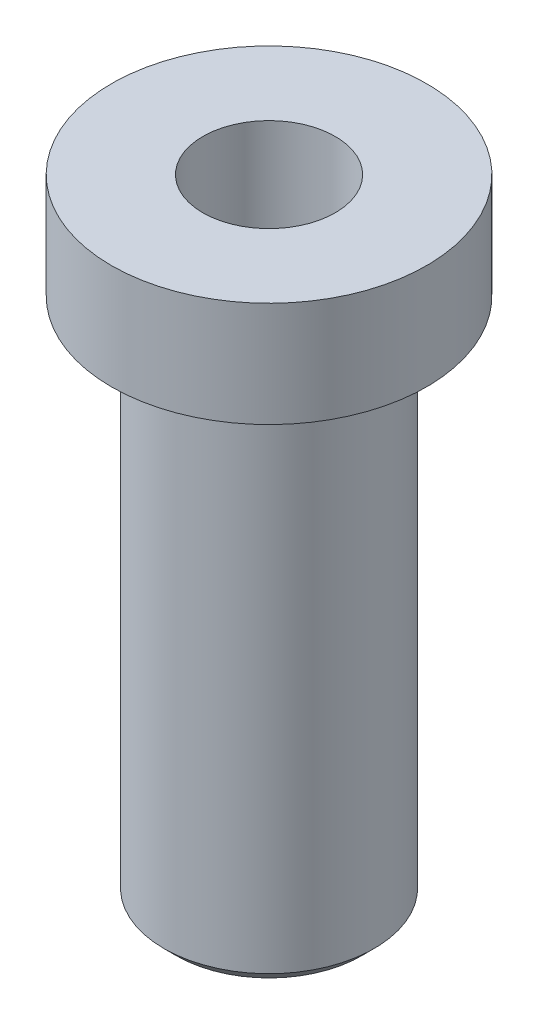
from build123d import *

# Parameters (mm, degrees)
SKETCH1_R           = 0.5
BOSS_EXTRUDE1_DEPTH = 3
SKETCH2_R           = 0.75
BOSS_EXTRUDE2_DEPTH = 0.5
CHAMFER1_SIZE       = 0.06
CUT_EXTRUDE1_START  = 3
SKETCH3_R           = 0.315
CUT_EXTRUDE1_DEPTH  = 4


with BuildPart() as part:
    # Sketch1 → Boss-Extrude1 (new body)
    with BuildSketch(Plane(origin=(0, 0, 0), x_dir=(1, 0, 0), z_dir=(0, 1, 0))):
        Circle(SKETCH1_R)
    extrude(amount=BOSS_EXTRUDE1_DEPTH)

    # Sketch2 → Boss-Extrude2 (add)
    with BuildSketch(Plane(origin=(0, 3, 0), x_dir=(1, 0, 0), z_dir=(0, 1, 0))):
        Circle(SKETCH2_R)
    extrude(amount=-BOSS_EXTRUDE2_DEPTH)

    # Chamfer1
    chamfer1_edges = [part.edges().sort_by_distance(p)[0] for p in [
        (-0.5, 0, 0),
    ]]
    chamfer(chamfer1_edges, length=CHAMFER1_SIZE)

    # Sketch3 → Cut-Extrude1 (cut, through all)
    with BuildSketch(Plane(origin=(0, 0, 0), x_dir=(1, 0, 0), z_dir=(0, 1, 0)).offset(CUT_EXTRUDE1_START)):
        Circle(SKETCH3_R)
    extrude(amount=-CUT_EXTRUDE1_DEPTH, mode=Mode.SUBTRACT)


solid = part.part
